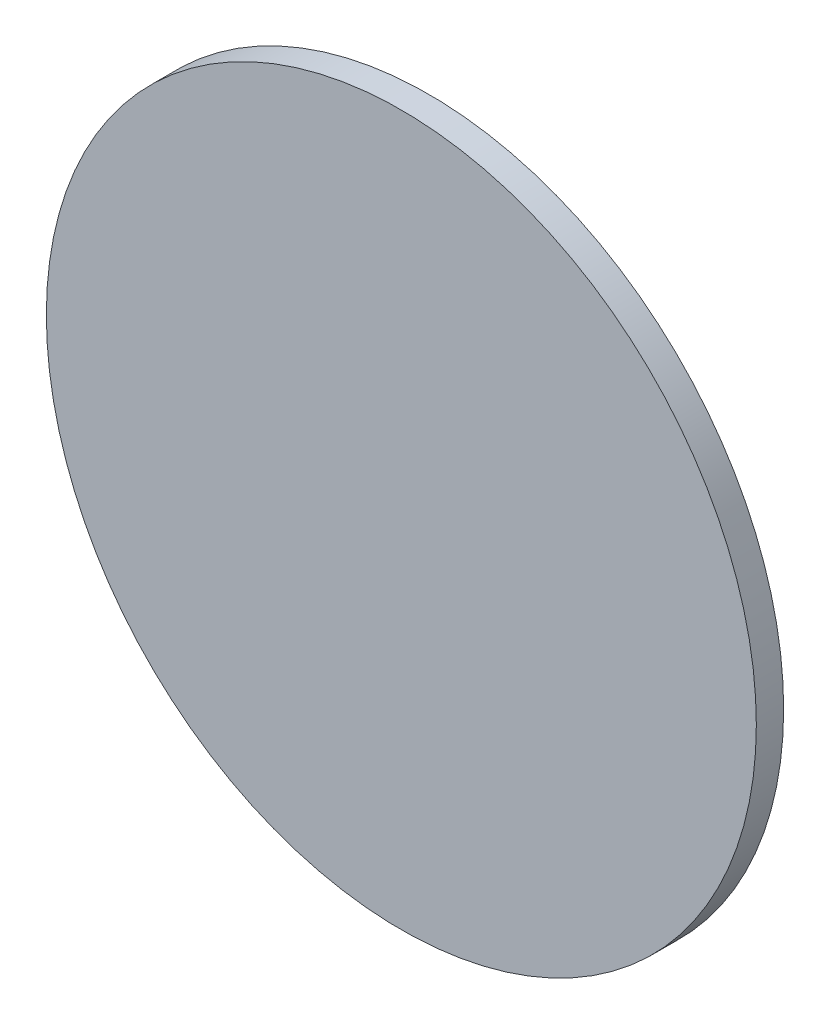
from build123d import *

# Parameters (mm, degrees)
SKETCH1_R           = 165.062282849
BOSS_EXTRUDE1_DEPTH = 12.7


with BuildPart() as part:
    # Sketch1 → Boss-Extrude1 (new body)
    with BuildSketch(Plane.XY):
        with Locations((-31.532687059, 19.91445928)):
            Circle(SKETCH1_R)
    extrude(amount=BOSS_EXTRUDE1_DEPTH)


solid = part.part
